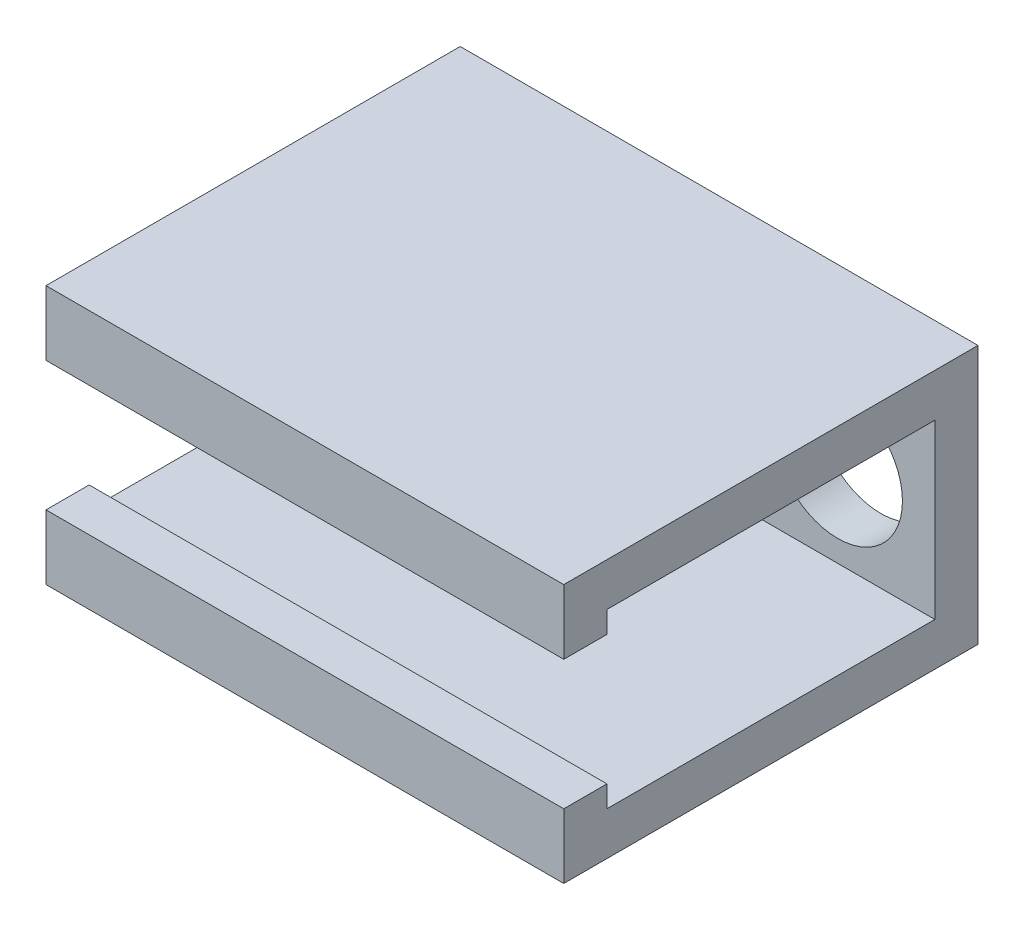
from build123d import *

# Parameters (mm, degrees)
BOSS_EXTRUDE1_DEPTH = 60
SKETCH3_R           = 7.5
CUT_EXTRUDE1_DEPTH  = 49


with BuildPart() as part:
    # Sketch1 → Boss-Extrude1 (new body)
    with BuildSketch(Plane(origin=(0, 0, 0), x_dir=(0, 0, -1), z_dir=(1, 0, 0))):
        Polygon((-5, 7.5), (0, 7.5), (0, 10), (38, 10), (38, 0), (43, 0), (43, 15), (-5, 15), align=None)
        Polygon((43, 0), (38, 0), (38, -10), (0, -10), (0, -7.5), (-5, -7.5), (-5, -15), (43, -15), align=None)
    extrude(amount=BOSS_EXTRUDE1_DEPTH)

    # Sketch3 → Cut-Extrude1 (cut, through all)
    with BuildSketch(Plane(origin=(0, 0, -43), x_dir=(-1, 0, 0), z_dir=(0, 0, -1))):
        with Locations((-48.743612904, 0)):
            Circle(SKETCH3_R)
    extrude(amount=-CUT_EXTRUDE1_DEPTH, mode=Mode.SUBTRACT)


solid = part.part
